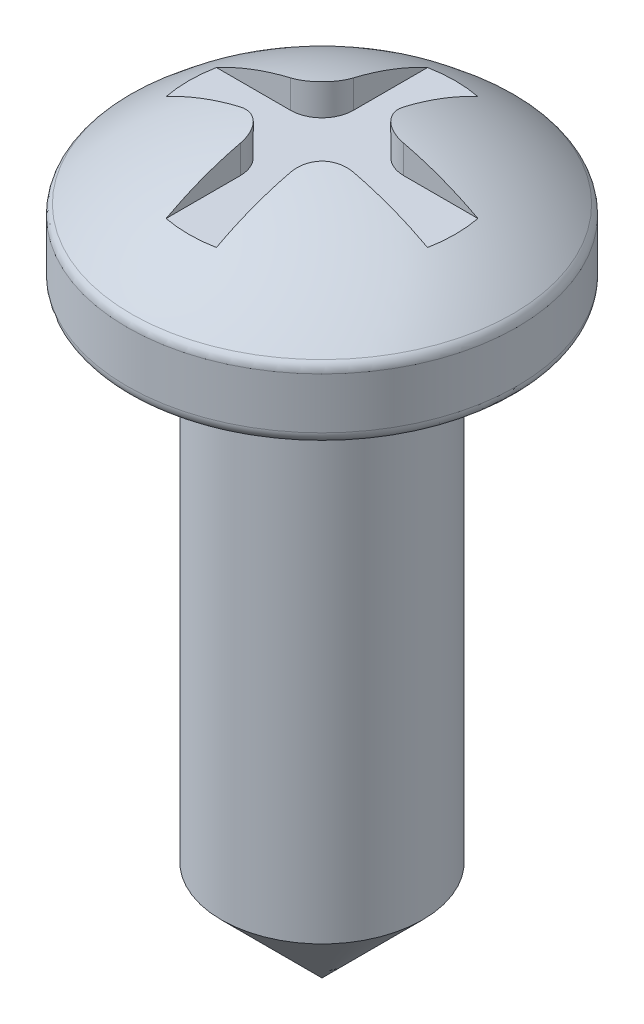
from build123d import *

# Parameters (mm, degrees)
CORTAR_EXTRUIR1_START = -1.8
CORTAR_EXTRUIR1_DEPTH = 3


with BuildPart() as part:
    # Croquis1 → Revolución1 (revolve)
    with BuildSketch(Plane.XY):
        with BuildLine():
            Line((0, 0), (0, 11.9))
            ThreePointArc((0, 11.9), (1.620417383, 11.535759883), (3.032129542, 10.660835807))
            ThreePointArc((3.032129542, 10.660835807), (3.082244216, 10.59308012), (3.1, 10.510696592))
            Line((3.1, 10.510696592), (3.1, 9.7))
            ThreePointArc((3.1, 9.7), (3.041421356, 9.558578644), (2.9, 9.5))
            Line((2.9, 9.5), (1.6, 9.5))
            Line((1.6, 9.5), (1.6, 1.6))
            Line((1.6, 1.6), (0, 0))
        make_face()
    revolve(axis=Axis((0, 0, 0), (0, 1, 0)))

    # Croquis2 → Cortar-Extruir1 (cut)
    with BuildSketch(Plane.XZ.offset(-9.5).offset(CORTAR_EXTRUIR1_START)):
        with BuildLine():
            Line((-0.4, 3.2), (-0.4, 0.9))
            ThreePointArc((-0.4, 0.9), (-0.546446609, 0.546446609), (-0.9, 0.4))
            Line((-0.9, 0.4), (-3.2, 0.4))
            Line((-3.2, 0.4), (-3.2, -0.4))
            Line((-3.2, -0.4), (-0.9, -0.4))
            ThreePointArc((-0.9, -0.4), (-0.546446609, -0.546446609), (-0.4, -0.9))
            Line((-0.4, -0.9), (-0.4, -3.2))
            Line((-0.4, -3.2), (0.4, -3.2))
            Line((0.4, -3.2), (0.4, -0.9))
            ThreePointArc((0.4, -0.9), (0.546446609, -0.546446609), (0.9, -0.4))
            Line((0.9, -0.4), (3.2, -0.4))
            Line((3.2, -0.4), (3.2, 0.4))
            Line((3.2, 0.4), (0.9, 0.4))
            ThreePointArc((0.9, 0.4), (0.546446609, 0.546446609), (0.4, 0.9))
            Line((0.4, 0.9), (0.4, 3.2))
            Line((0.4, 3.2), (-0.4, 3.2))
        make_face()
    extrude(amount=-CORTAR_EXTRUIR1_DEPTH, mode=Mode.SUBTRACT)


solid = part.part
